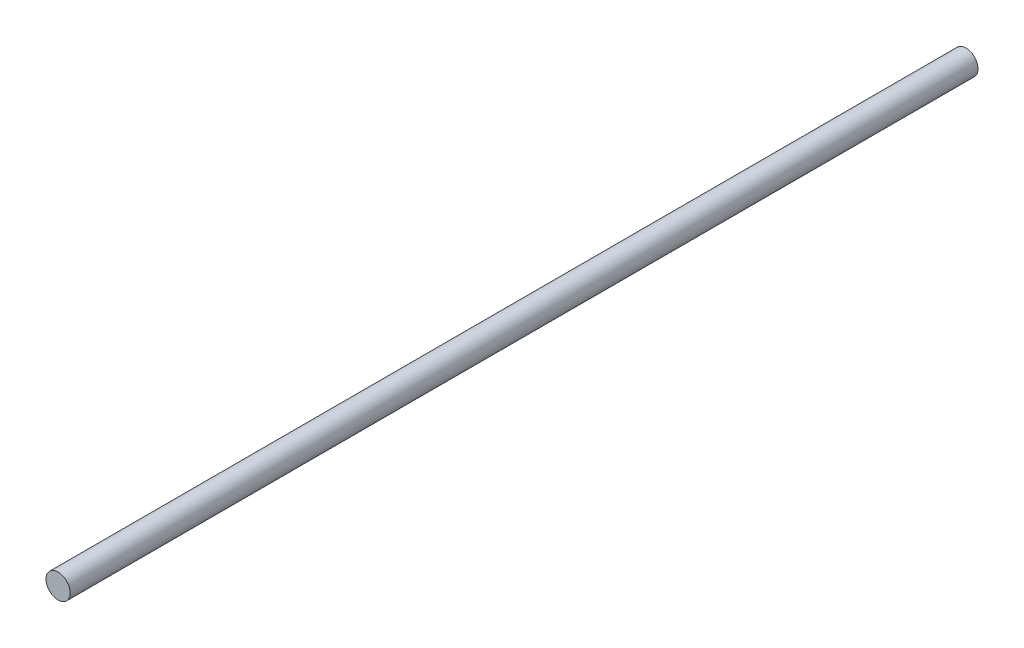
from build123d import *

# Parameters (mm, degrees)
SKETCH1_R           = 3.175
BOSS_EXTRUDE1_DEPTH = 238.125


with BuildPart() as part:
    # Sketch1 → Boss-Extrude1 (new body)
    with BuildSketch(Plane.XY):
        Circle(SKETCH1_R)
    extrude(amount=BOSS_EXTRUDE1_DEPTH)


solid = part.part
